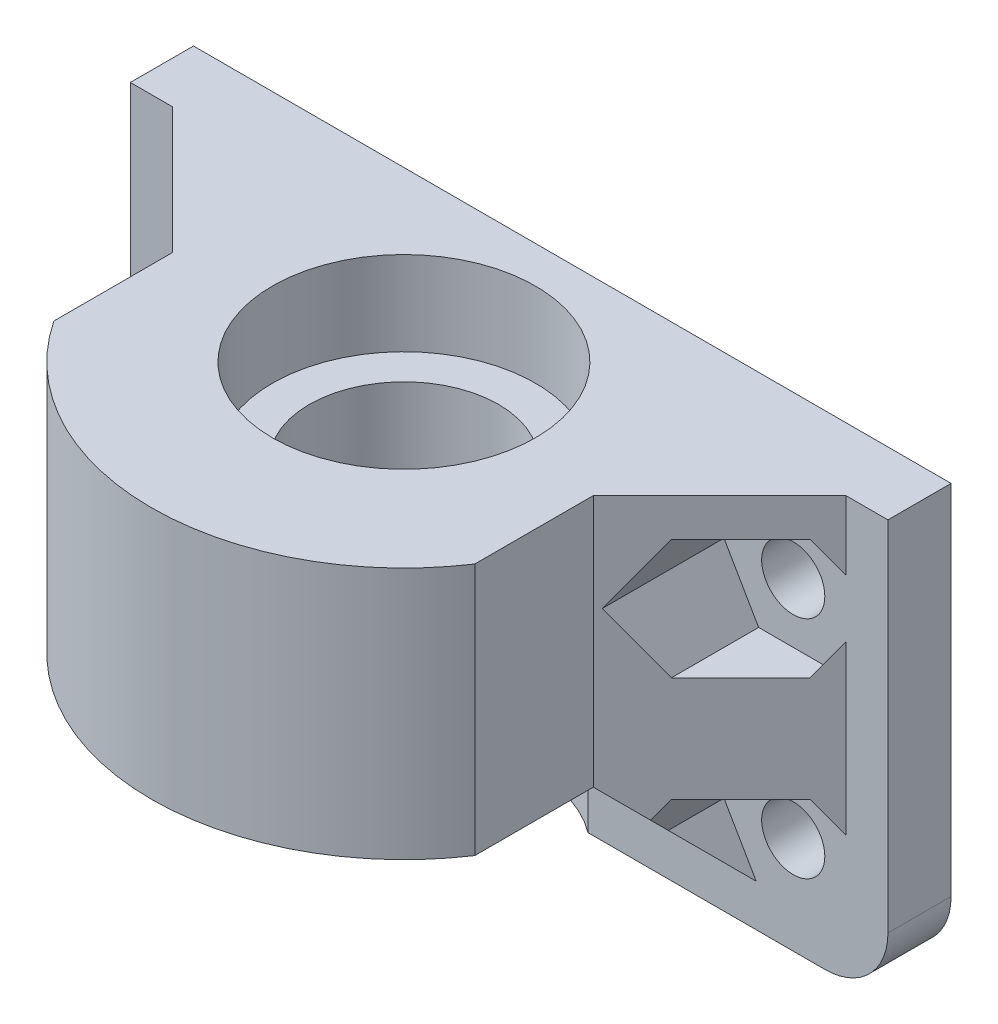
from build123d import *

# Parameters (mm, degrees)
SKETCH1_W           = 20
SKETCH1_H           = 12
BOSS_EXTRUDE1_DEPTH = 20
SKETCH2_R           = 3
CUT_EXTRUDE1_DEPTH  = 13
SKETCH3_R           = 6.25
CUT_EXTRUDE2_DEPTH  = 4
SKETCH4_R           = 4.5
CUT_EXTRUDE3_DEPTH  = 9
SKETCH5_R           = 6.25
CUT_EXTRUDE4_DEPTH  = 4
BOSS_EXTRUDE2_DEPTH = 3
SKETCH7_R           = 6.25
CUT_EXTRUDE5_DEPTH  = 12
CHAMFER1_SIZE       = 6
CUT_EXTRUDE6_DEPTH  = 14
SKETCH9_W           = 3.789335489
SKETCH9_H           = 4.098961347
CUT_EXTRUDE7_DEPTH  = 2
SKETCH10_R          = 1.5
CUT_EXTRUDE8_DEPTH  = 4
CUT_EXTRUDE9_DEPTH  = 13
FILLET1_R           = 3


with BuildPart() as part:
    # Sketch1 → Boss-Extrude1 (new body)
    with BuildSketch(Plane.XY):
        with Locations((-59.5, -44)):
            Rectangle(SKETCH1_W, SKETCH1_H)
    extrude(amount=BOSS_EXTRUDE1_DEPTH)

    # Sketch2 → Cut-Extrude1 (cut, through all)
    with BuildSketch(Plane.XZ.offset(50)):
        with Locations((-59.5, 8)):
            Circle(SKETCH2_R)
    extrude(amount=-CUT_EXTRUDE1_DEPTH, mode=Mode.SUBTRACT)

    # Sketch3 → Cut-Extrude2 (cut)
    with BuildSketch(Plane.XZ.offset(50)):
        with Locations((-59.5, 8)):
            Circle(SKETCH3_R)
    extrude(amount=-CUT_EXTRUDE2_DEPTH, mode=Mode.SUBTRACT)

    # Sketch4 → Cut-Extrude3 (cut, through all)
    with BuildSketch(Plane.XZ.offset(46)):
        with Locations((-59.5, 8)):
            Circle(SKETCH4_R)
    extrude(amount=-CUT_EXTRUDE3_DEPTH, mode=Mode.SUBTRACT)

    # Sketch5 → Cut-Extrude4 (cut)
    with BuildSketch(Plane(origin=(0, -38, 0), x_dir=(1, 0, 0), z_dir=(0, 1, 0))):
        with Locations((-59.5, -8)):
            Circle(SKETCH5_R)
    extrude(amount=-CUT_EXTRUDE4_DEPTH, mode=Mode.SUBTRACT)

    # Sketch6 → Boss-Extrude2 (add)
    with BuildSketch(Plane(origin=(0, 0, 0), x_dir=(-1, 0, 0), z_dir=(0, 0, -1))):
        Polygon((49.5, -38), (41.5, -38), (41.5, -58), (77.5, -58), (77.5, -38), (69.5, -38), (69.5, -50), (49.5, -50), align=None)
    extrude(amount=-BOSS_EXTRUDE2_DEPTH)

    # Sketch7 → Cut-Extrude5 (cut)
    with BuildSketch(Plane.XZ.offset(58)):
        with Locations((-59.5, 8)):
            Circle(SKETCH7_R)
    extrude(amount=-CUT_EXTRUDE5_DEPTH, mode=Mode.SUBTRACT)

    # Chamfer1
    chamfer1_edges = [part.edges().sort_by_distance(p)[0] for p in [
        (-49.5, -44, 3),
        (-66.375, -50, 3),
        (-52.625, -50, 3),
        (-69.5, -44, 3),
    ]]
    chamfer(chamfer1_edges, length=CHAMFER1_SIZE)

    # Sketch8 → Cut-Extrude6 (cut)
    with BuildSketch(Plane.XY.offset(3)):
        Polygon((-47.645448267, -39.8), (-49.290896534, -42.65), (-47.645448267, -45.5), (-44.354551733, -45.5), (-42.709103466, -42.65), (-44.354551733, -39.8), align=None)
        Polygon((-47.645448267, -50.5), (-49.290896534, -53.35), (-47.645448267, -56.2), (-44.354551733, -56.2), (-42.709103466, -53.35), (-44.354551733, -50.5), align=None)
        Polygon((-74.645448267, -50.5), (-71.354551733, -50.5), (-69.709103466, -53.35), (-71.354551733, -56.2), (-74.645448267, -56.2), (-76.290896534, -53.35), align=None)
        Polygon((-74.645448267, -39.8), (-71.354551733, -39.8), (-69.709103466, -42.65), (-71.354551733, -45.5), (-74.645448267, -45.5), (-76.290896534, -42.65), align=None)
    extrude(amount=CUT_EXTRUDE6_DEPTH, mode=Mode.SUBTRACT)

    # Sketch9 → Cut-Extrude7 (cut)
    with BuildSketch(Plane.XY.offset(3)):
        with Locations((-43.394667744, -55.950519327)):
            Rectangle(SKETCH9_W, SKETCH9_H)
        with Locations((-75.605332256, -55.950519327)):
            Rectangle(SKETCH9_W, SKETCH9_H)
    extrude(amount=CUT_EXTRUDE7_DEPTH, mode=Mode.SUBTRACT)

    # Sketch10 → Cut-Extrude8 (cut, through all)
    with BuildSketch(Plane.XY.offset(3)):
        with Locations((-73, -42.65)):
            Circle(SKETCH10_R)
        with Locations((-73, -53.35)):
            Circle(SKETCH10_R)
        with Locations((-46, -53.35)):
            Circle(SKETCH10_R)
        with Locations((-46, -42.65)):
            Circle(SKETCH10_R)
    extrude(amount=-CUT_EXTRUDE8_DEPTH, mode=Mode.SUBTRACT)

    # Sketch11 → Cut-Extrude9 (cut, through all)
    with BuildSketch(Plane.XZ.offset(50)):
        with BuildLine():
            Line((-69.5, 20), (-69.5, 14.633249581))
            ThreePointArc((-69.5, 14.633249581), (-65.174548662, 18.573528147), (-59.5, 20))
            Line((-59.5, 20), (-69.5, 20))
        make_face()
        with BuildLine():
            ThreePointArc((-59.5, 20), (-53.825451338, 18.573528147), (-49.5, 14.633249581))
            Line((-49.5, 14.633249581), (-49.5, 20))
            Line((-49.5, 20), (-59.5, 20))
        make_face()
    extrude(amount=-CUT_EXTRUDE9_DEPTH, mode=Mode.SUBTRACT)

    # Fillet1
    fillet1_edges = [part.edges().sort_by_distance(p)[0] for p in [
        (-77.5, -58, 1.5),
        (-41.5, -58, 1.5),
    ]]
    fillet(fillet1_edges, radius=FILLET1_R)


solid = part.part
